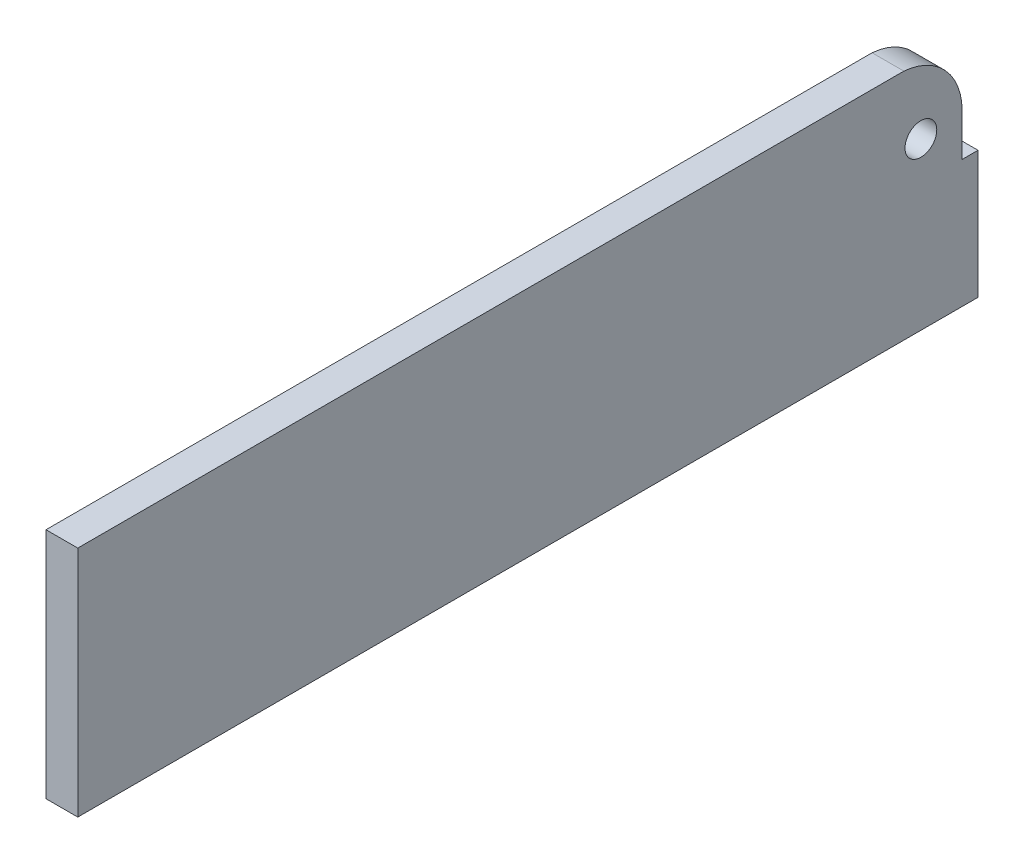
from build123d import *

# Parameters (mm, degrees)
SKETCH1_R           = 1.5
BOSS_EXTRUDE1_DEPTH = 3


with BuildPart() as part:
    # Sketch1 → Boss-Extrude1 (new body)
    with BuildSketch(Plane(origin=(0, 0, 0), x_dir=(0, 0, -1), z_dir=(1, 0, 0))):
        with BuildLine():
            Line((41, 1.526420496), (42.5, 1.526420496))
            Line((42.5, 1.526420496), (42.5, -10.502465522))
            Line((42.5, -10.502465522), (-42.5, -10.502465522))
            Line((-42.5, -10.502465522), (-42.5, 11.497534478))
            Line((-42.5, 11.497534478), (35.5, 11.497534478))
            ThreePointArc((35.5, 11.497534478), (39.415467178, 9.585490654), (41, 5.526420496))
            Line((41, 5.526420496), (41, 1.526420496))
        make_face()
        with Locations((37.107006816, 5.147769804)):
            Circle(SKETCH1_R, mode=Mode.SUBTRACT)
    extrude(amount=BOSS_EXTRUDE1_DEPTH)


solid = part.part
